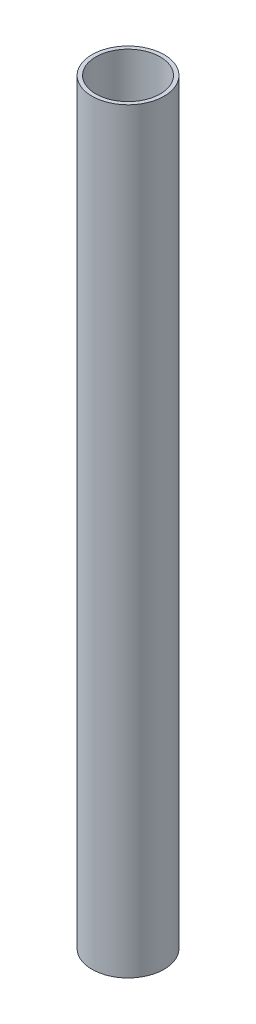
from build123d import *

# Parameters (mm, degrees)
SKETCH1_W = 0.381
SKETCH1_H = 74.6125


with BuildPart() as part:
    # Sketch1 → Revolve1 (revolve)
    with BuildSketch(Plane.XY):
        with Locations((-3.3655, 37.30625)):
            Rectangle(SKETCH1_W, SKETCH1_H)
    revolve(axis=Axis((0, 0, 0), (0, 1, 0)))


solid = part.part
